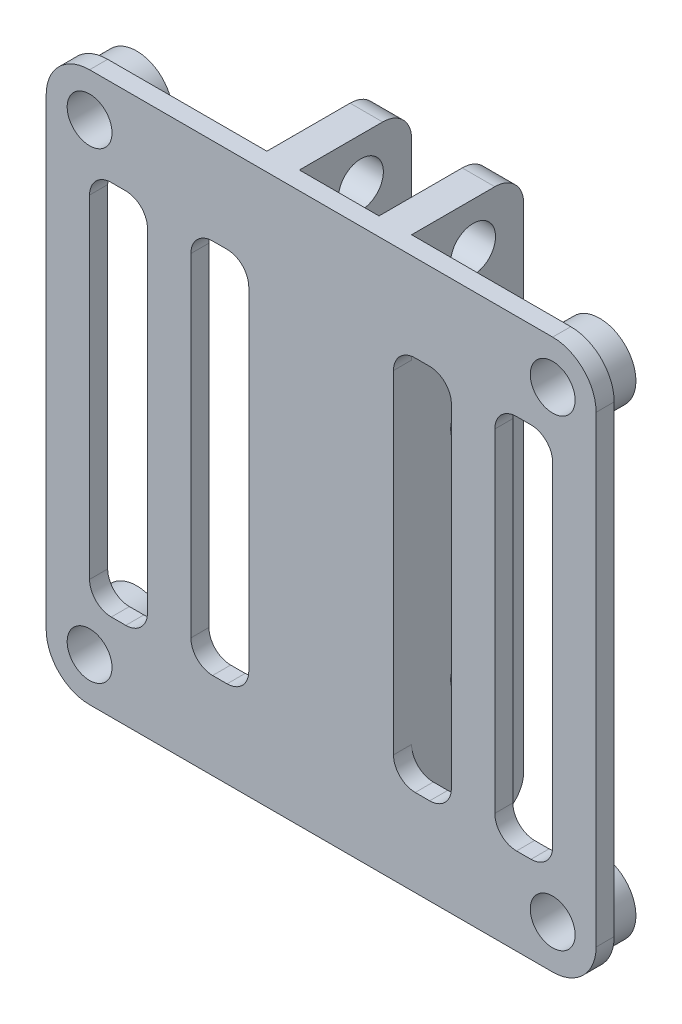
from build123d import *

# Parameters (mm, degrees)
ESQUISSE1_W                  = 38
ESQUISSE1_H                  = 38
BOSS_EXTRU_1_DEPTH           = 9
ESQUISSE2_W                  = 14
ESQUISSE2_H                  = 38
ESQUISSE2_W_2                = 5.5
ENL_V_MAT_EXTRU_1_DEPTH      = 7.75
ESQUISSE3_R                  = 1.55
ENL_V_MAT_EXTRU_2_DEPTH      = 25
CONG_1_R                     = 3
CONG_2_R                     = 2
ESQUISSE9_R                  = 2.5
BOSS_EXTRU_2_DEPTH           = 2
ESQUISSE5_R                  = 1.55
ENL_V_MAT_EXTRU_4_DEPTH      = 8.75
ENL_V_MAT_EXTRU_4_DEPTH_BACK = 2.25
ESQUISSE10_W                 = 4
ESQUISSE10_H                 = 26
ENL_V_MAT_EXTRU_5_DEPTH      = 10
CONG_3_R                     = 1.5


with BuildPart() as part:
    # Esquisse1 → Boss.-Extru.1 (new body)
    with BuildSketch(Plane.XY):
        with Locations((19, 19)):
            Rectangle(ESQUISSE1_W, ESQUISSE1_H)
    extrude(amount=BOSS_EXTRU_1_DEPTH)

    # Esquisse2 → Enlèv. mat.-Extru.1 (cut)
    with BuildSketch(Plane(origin=(0, 0, 0), x_dir=(-1, 0, 0), z_dir=(0, 0, -1))):
        with Locations((-7, 19)):
            Rectangle(ESQUISSE2_W, ESQUISSE2_H)
        with Locations((-31, 19)):
            Rectangle(ESQUISSE2_W, ESQUISSE2_H)
        with Locations((-19, 19)):
            Rectangle(ESQUISSE2_W_2, ESQUISSE2_H)
    extrude(amount=-ENL_V_MAT_EXTRU_1_DEPTH, mode=Mode.SUBTRACT)

    # Esquisse3 → Enlèv. mat.-Extru.2 (cut, through all)
    with BuildSketch(Plane(origin=(24, 0, 0), x_dir=(0, 0, -1), z_dir=(1, 0, 0))):
        with Locations((-3.5, 10)):
            Circle(ESQUISSE3_R)
        with Locations((-3.5, 35)):
            Circle(ESQUISSE3_R)
        with Locations((-3.5, 25)):
            Circle(ESQUISSE3_R)
    extrude(amount=-ENL_V_MAT_EXTRU_2_DEPTH, mode=Mode.SUBTRACT)

    # Congé1
    cong_1_edges = [part.edges().sort_by_distance(p)[0] for p in [
        (0, 38, 8.375),
        (38, 38, 8.375),
        (38, 0, 8.375),
        (0, 0, 8.375),
    ]]
    fillet(cong_1_edges, radius=CONG_1_R)

    # Congé2
    cong_2_edges = [part.edges().sort_by_distance(p)[0] for p in [
        (22.875, 38, 0),
        (15.125, 38, 0),
        (15.125, 0, 0),
        (22.875, 0, 0),
    ]]
    fillet(cong_2_edges, radius=CONG_2_R)

    # Esquisse9 → Boss.-Extru.2 (add)
    with BuildSketch(Plane(origin=(0, 0, 7.75), x_dir=(-1, 0, 0), z_dir=(0, 0, -1))):
        with Locations((-35, 35)):
            Circle(ESQUISSE9_R)
        with Locations((-3, 35)):
            Circle(ESQUISSE9_R)
        with Locations((-3, 3)):
            Circle(ESQUISSE9_R)
        with Locations((-35, 3)):
            Circle(ESQUISSE9_R)
    extrude(amount=BOSS_EXTRU_2_DEPTH)

    # Esquisse5 → Enlèv. mat.-Extru.4 (cut, two sides)
    with BuildSketch(Plane(origin=(0, 0, 7.75), x_dir=(-1, 0, 0), z_dir=(0, 0, -1))) as enl_v_mat_extru_4_sk:
        with Locations((-35, 35)):
            Circle(ESQUISSE5_R)
        with Locations((-35, 3)):
            Circle(ESQUISSE5_R)
        with Locations((-3, 3)):
            Circle(ESQUISSE5_R)
        with Locations((-3, 35)):
            Circle(ESQUISSE5_R)
    extrude(amount=ENL_V_MAT_EXTRU_4_DEPTH, mode=Mode.SUBTRACT)
    extrude(enl_v_mat_extru_4_sk.sketch, amount=-ENL_V_MAT_EXTRU_4_DEPTH_BACK, mode=Mode.SUBTRACT)

    # Esquisse10 → Enlèv. mat.-Extru.5 (cut, through all)
    with BuildSketch(Plane.XY.offset(9)):
        with Locations((12, 19)):
            Rectangle(ESQUISSE10_W, ESQUISSE10_H)
        with Locations((5, 19)):
            Rectangle(ESQUISSE10_W, ESQUISSE10_H)
        with Locations((26, 19)):
            Rectangle(ESQUISSE10_W, ESQUISSE10_H)
        with Locations((33, 19)):
            Rectangle(ESQUISSE10_W, ESQUISSE10_H)
    extrude(amount=-ENL_V_MAT_EXTRU_5_DEPTH, mode=Mode.SUBTRACT)

    # Congé3
    cong_3_edges = [part.edges().sort_by_distance(p)[0] for p in [
        (3, 6, 8.375),
        (3, 32, 8.375),
        (7, 32, 8.375),
        (7, 6, 8.375),
        (24, 6, 8.375),
        (24, 32, 8.375),
        (28, 32, 8.375),
        (28, 6, 8.375),
        (35, 32, 8.375),
        (35, 6, 8.375),
        (31, 6, 8.375),
        (31, 32, 8.375),
        (14, 32, 8.375),
        (10, 6, 8.375),
        (10, 32, 8.375),
        (14, 6, 8.375),
    ]]
    fillet(cong_3_edges, radius=CONG_3_R)


solid = part.part
